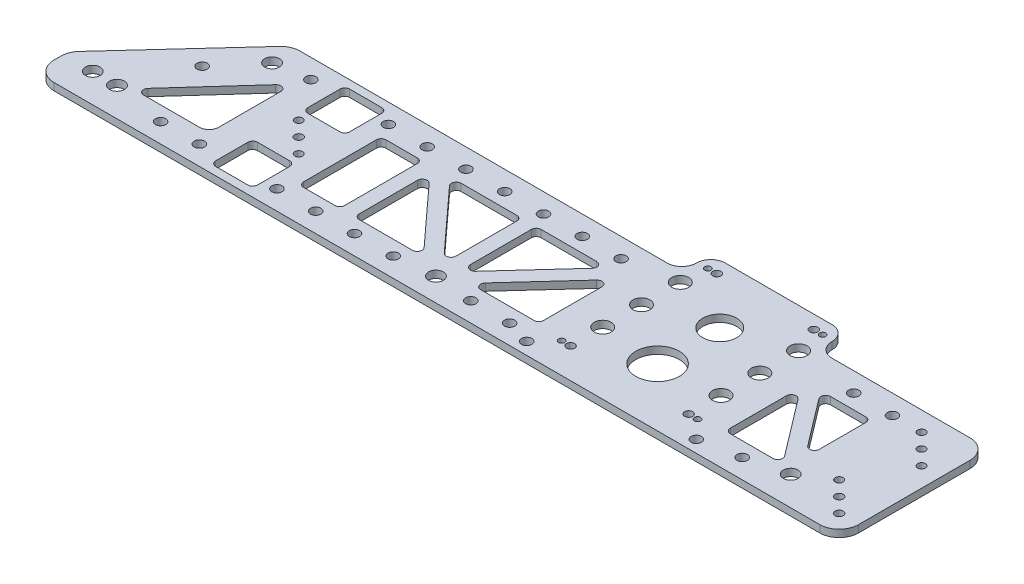
from build123d import *

# Parameters (mm, degrees)
SKETCH1_R           = 4.826
SKETCH1_R_2         = 5.5626
SKETCH1_R_3         = 14.28115
SKETCH1_R_4         = 11.10615
SKETCH1_R_5         = 3.3782
SKETCH1_R_6         = 2.667
SKETCH1_R_7         = 2.032
SKETCH1_R_8         = 2.5527
BOSS_EXTRUDE1_DEPTH = 4.7625


with BuildPart() as part:
    # Sketch1 → Boss-Extrude1 (new body)
    with BuildSketch(Plane.XZ):
        with BuildLine():
            Line((335.06917663, -117.475), (404.91917663, -117.475))
            ThreePointArc((404.91917663, -117.475), (411.654368721, -114.685192091), (414.44417663, -107.95))
            ThreePointArc((414.44417663, -107.95), (417.233984539, -101.214807909), (423.96917663, -98.425))
            Line((423.96917663, -98.425), (514.35, -98.425))
            ThreePointArc((514.35, -98.425), (523.330256121, -94.705256121), (527.05, -85.725))
            Line((527.05, -85.725), (527.05, -12.7))
            ThreePointArc((527.05, -12.7), (523.330256121, -3.719743879), (514.35, 0))
            Line((514.35, 0), (12.7, 0))
            ThreePointArc((12.7, 0), (3.719743879, -3.719743879), (0, -12.7))
            Line((0, -12.7), (0, -17.28490713))
            ThreePointArc((0, -17.28490713), (0.863919752, -21.888949307), (3.338142419, -25.866609912))
            Line((3.338142419, -25.866609912), (66.074894217, -94.306702782))
            ThreePointArc((66.074894217, -94.306702782), (70.322928635, -97.34992205), (75.436751798, -98.425))
            Line((75.436751798, -98.425), (316.01917663, -98.425))
            ThreePointArc((316.01917663, -98.425), (322.754368721, -101.214807909), (325.54417663, -107.95))
            ThreePointArc((325.54417663, -107.95), (328.333984539, -114.685192091), (335.06917663, -117.475))
        make_face()
        with Locations((34.925, -19.05)):
            Circle(SKETCH1_R, mode=Mode.SUBTRACT)
        with Locations((408.74516284, -66.3194)):
            Circle(SKETCH1_R_2, mode=Mode.SUBTRACT)
        with Locations((331.243190421, -40.9194)):
            Circle(SKETCH1_R_2, mode=Mode.SUBTRACT)
        with Locations((331.243190421, -66.3194)):
            Circle(SKETCH1_R_2, mode=Mode.SUBTRACT)
        with Locations((369.99417663, -38.1)):
            Circle(SKETCH1_R_3, mode=Mode.SUBTRACT)
        with Locations((247.65, -15.24)):
            Circle(SKETCH1_R, mode=Mode.SUBTRACT)
        with Locations((19.05, -19.05)):
            Circle(SKETCH1_R, mode=Mode.SUBTRACT)
        with Locations((476.25, -19.05)):
            Circle(SKETCH1_R, mode=Mode.SUBTRACT)
        with Locations((369.99417663, -78.8162)):
            Circle(SKETCH1_R_4, mode=Mode.SUBTRACT)
        with Locations((331.243190421, -91.7194)):
            Circle(SKETCH1_R_2, mode=Mode.SUBTRACT)
        with Locations((408.74516284, -91.7194)):
            Circle(SKETCH1_R_2, mode=Mode.SUBTRACT)
        with Locations((408.74516284, -40.9194)):
            Circle(SKETCH1_R_2, mode=Mode.SUBTRACT)
        with Locations((314.41897663, -7.9248)):
            Circle(SKETCH1_R_5, mode=Mode.SUBTRACT)
        with Locations((338.24417663, -108.6612)):
            Circle(SKETCH1_R_6, mode=Mode.SUBTRACT)
        with Locations((425.56937663, -7.9248)):
            Circle(SKETCH1_R_5, mode=Mode.SUBTRACT)
        with Locations((401.74417663, -108.6612)):
            Circle(SKETCH1_R_6, mode=Mode.SUBTRACT)
        with Locations((331.33537663, -19.7866)):
            Circle(SKETCH1_R_6, mode=Mode.SUBTRACT)
        with Locations((408.65297663, -19.7866)):
            Circle(SKETCH1_R_6, mode=Mode.SUBTRACT)
        with Locations((332.40217663, -108.6612)):
            Circle(SKETCH1_R_7, mode=Mode.SUBTRACT)
        with Locations((325.49337663, -19.7866)):
            Circle(SKETCH1_R_7, mode=Mode.SUBTRACT)
        with Locations((407.58617663, -108.6612)):
            Circle(SKETCH1_R_7, mode=Mode.SUBTRACT)
        with Locations((414.49497663, -19.7866)):
            Circle(SKETCH1_R_7, mode=Mode.SUBTRACT)
        with Locations((73.025, -82.55)):
            Circle(SKETCH1_R, mode=Mode.SUBTRACT)
        with Locations((95.25, -12.7)):
            Circle(SKETCH1_R_5, mode=Mode.SUBTRACT)
        with Locations((95.25, -85.725)):
            Circle(SKETCH1_R_5, mode=Mode.SUBTRACT)
        with Locations((146.05, -12.7)):
            Circle(SKETCH1_R_5, mode=Mode.SUBTRACT)
        with Locations((146.05, -85.725)):
            Circle(SKETCH1_R_5, mode=Mode.SUBTRACT)
        with Locations((171.45, -12.7)):
            Circle(SKETCH1_R_5, mode=Mode.SUBTRACT)
        with Locations((171.45, -85.725)):
            Circle(SKETCH1_R_5, mode=Mode.SUBTRACT)
        with Locations((196.85, -12.7)):
            Circle(SKETCH1_R_5, mode=Mode.SUBTRACT)
        with Locations((196.85, -85.725)):
            Circle(SKETCH1_R_5, mode=Mode.SUBTRACT)
        with Locations((222.25, -12.7)):
            Circle(SKETCH1_R_5, mode=Mode.SUBTRACT)
        with Locations((222.25, -85.725)):
            Circle(SKETCH1_R_5, mode=Mode.SUBTRACT)
        with Locations((247.65, -85.725)):
            Circle(SKETCH1_R_5, mode=Mode.SUBTRACT)
        with Locations((273.05, -12.7)):
            Circle(SKETCH1_R_5, mode=Mode.SUBTRACT)
        with Locations((273.05, -85.725)):
            Circle(SKETCH1_R_5, mode=Mode.SUBTRACT)
        with Locations((298.45, -12.7)):
            Circle(SKETCH1_R_5, mode=Mode.SUBTRACT)
        with Locations((298.45, -85.725)):
            Circle(SKETCH1_R_5, mode=Mode.SUBTRACT)
        with Locations((450.85, -12.7)):
            Circle(SKETCH1_R_5, mode=Mode.SUBTRACT)
        with Locations((476.25, -85.725)):
            Circle(SKETCH1_R_5, mode=Mode.SUBTRACT)
        with Locations((450.85, -85.725)):
            Circle(SKETCH1_R_5, mode=Mode.SUBTRACT)
        with Locations((495.3, -85.725)):
            Circle(SKETCH1_R_8, mode=Mode.SUBTRACT)
        with Locations((504.825, -76.2)):
            Circle(SKETCH1_R_8, mode=Mode.SUBTRACT)
        with Locations((514.35, -66.675)):
            Circle(SKETCH1_R_8, mode=Mode.SUBTRACT)
        with Locations((504.825, -22.225)):
            Circle(SKETCH1_R_6, mode=Mode.SUBTRACT)
        with Locations((495.3, -31.75)):
            Circle(SKETCH1_R_8, mode=Mode.SUBTRACT)
        with Locations((514.35, -12.7)):
            Circle(SKETCH1_R_6, mode=Mode.SUBTRACT)
        with Locations((123.825, -49.2125)):
            Circle(SKETCH1_R_6, mode=Mode.SUBTRACT)
        with Locations((133.35, -39.6875)):
            Circle(SKETCH1_R_8, mode=Mode.SUBTRACT)
        with Locations((114.3, -58.7375)):
            Circle(SKETCH1_R_8, mode=Mode.SUBTRACT)
        with Locations((69.85, -12.7)):
            Circle(SKETCH1_R_5, mode=Mode.SUBTRACT)
        with Locations((51.950539741, -57.756517342)):
            Circle(SKETCH1_R_5, mode=Mode.SUBTRACT)
        with BuildLine():
            Line((137.541, -68.834), (137.541, -89.916))
            ThreePointArc((137.541, -89.916), (136.61106403, -92.16106403), (134.366, -93.091))
            Line((134.366, -93.091), (113.284, -93.091))
            ThreePointArc((113.284, -93.091), (111.03893597, -92.16106403), (110.109, -89.916))
            Line((110.109, -89.916), (110.109, -68.834))
            ThreePointArc((110.109, -68.834), (111.03893597, -66.58893597), (113.284, -65.659))
            Line((113.284, -65.659), (134.366, -65.659))
            ThreePointArc((134.366, -65.659), (136.61106403, -66.58893597), (137.541, -68.834))
        make_face(mode=Mode.SUBTRACT)
        with BuildLine():
            Line((137.541, -8.509), (137.541, -29.591))
            ThreePointArc((137.541, -29.591), (136.61106403, -31.83606403), (134.366, -32.766))
            Line((134.366, -32.766), (113.284, -32.766))
            ThreePointArc((113.284, -32.766), (111.03893597, -31.83606403), (110.109, -29.591))
            Line((110.109, -29.591), (110.109, -8.509))
            ThreePointArc((110.109, -8.509), (111.03893597, -6.26393597), (113.284, -5.334))
            Line((113.284, -5.334), (134.366, -5.334))
            ThreePointArc((134.366, -5.334), (136.61106403, -6.26393597), (137.541, -8.509))
        make_face(mode=Mode.SUBTRACT)
        with BuildLine():
            Line((86.545623901, -71.37201882), (46.879170981, -27.530149804))
            ThreePointArc((46.879170981, -27.530149804), (46.33149172, -24.112094846), (49.23354708, -22.225))
            Line((49.23354708, -22.225), (85.725, -22.225))
            ThreePointArc((85.725, -22.225), (90.215128061, -24.084871939), (92.075, -28.575))
            Line((92.075, -28.575), (92.075, -69.241869017))
            ThreePointArc((92.075, -69.241869017), (90.041376556, -72.204618509), (86.545623901, -71.37201882))
        make_face(mode=Mode.SUBTRACT)
        with BuildLine():
            Line((463.980698305, -27.321322562), (436.034552363, -64.087036098))
            ThreePointArc((436.034552363, -64.087036098), (432.493157106, -65.174533525), (430.33187663, -62.165713536))
            Line((430.33187663, -62.165713536), (430.33187663, -25.4))
            ThreePointArc((430.33187663, -25.4), (431.2618126, -23.15493597), (433.50687663, -22.225))
            Line((433.50687663, -22.225), (461.453022572, -22.225))
            ThreePointArc((461.453022572, -22.225), (464.297387539, -23.989250932), (463.980698305, -27.321322562))
        make_face(mode=Mode.SUBTRACT)
        with BuildLine():
            Line((292.051741244, -76.2), (255.5875, -76.2))
            ThreePointArc((255.5875, -76.2), (253.34243597, -75.27006403), (252.4125, -73.025))
            Line((252.4125, -73.025), (252.4125, -33.144184818))
            ThreePointArc((252.4125, -33.144184818), (254.43837015, -30.184433885), (257.930689347, -31.001735592))
            Line((257.930689347, -31.001735592), (294.394930591, -70.882550774))
            ThreePointArc((294.394930591, -70.882550774), (294.957158709, -74.305302446), (292.051741244, -76.2))
        make_face(mode=Mode.SUBTRACT)
        with BuildLine():
            Line((270.017235386, -22.225), (304.89397663, -22.225))
            ThreePointArc((304.89397663, -22.225), (307.13904066, -23.15493597), (308.06897663, -25.4))
            Line((308.06897663, -25.4), (308.06897663, -63.544571894))
            ThreePointArc((308.06897663, -63.544571894), (306.04310648, -66.504322828), (302.550787284, -65.68702112))
            Line((302.550787284, -65.68702112), (267.674046039, -27.542449226))
            ThreePointArc((267.674046039, -27.542449226), (267.111817921, -24.119697554), (270.017235386, -22.225))
        make_face(mode=Mode.SUBTRACT)
        with BuildLine():
            Line((239.7125, -76.2), (203.248258756, -76.2))
            ThreePointArc((203.248258756, -76.2), (200.342841291, -74.305302446), (200.905069409, -70.882550774))
            Line((200.905069409, -70.882550774), (237.369310653, -31.001735592))
            ThreePointArc((237.369310653, -31.001735592), (240.86162985, -30.184433885), (242.8875, -33.144184818))
            Line((242.8875, -33.144184818), (242.8875, -73.025))
            ThreePointArc((242.8875, -73.025), (241.95756403, -75.27006403), (239.7125, -76.2))
        make_face(mode=Mode.SUBTRACT)
        with BuildLine():
            Line((190.40602337, -22.225), (225.282764614, -22.225))
            ThreePointArc((225.282764614, -22.225), (228.188182079, -24.119697554), (227.625953961, -27.542449226))
            Line((227.625953961, -27.542449226), (192.749212716, -65.68702112))
            ThreePointArc((192.749212716, -65.68702112), (189.25689352, -66.504322828), (187.23102337, -63.544571894))
            Line((187.23102337, -63.544571894), (187.23102337, -25.4))
            ThreePointArc((187.23102337, -25.4), (188.16095934, -23.15493597), (190.40602337, -22.225))
        make_face(mode=Mode.SUBTRACT)
        with BuildLine():
            Line((177.70602337, -25.4), (177.70602337, -73.025))
            ThreePointArc((177.70602337, -73.025), (176.7760874, -75.27006403), (174.53102337, -76.2))
            Line((174.53102337, -76.2), (153.9875, -76.2))
            ThreePointArc((153.9875, -76.2), (151.74243597, -75.27006403), (150.8125, -73.025))
            Line((150.8125, -73.025), (150.8125, -25.4))
            ThreePointArc((150.8125, -25.4), (151.74243597, -23.15493597), (153.9875, -22.225))
            Line((153.9875, -22.225), (174.53102337, -22.225))
            ThreePointArc((174.53102337, -22.225), (176.7760874, -23.15493597), (177.70602337, -25.4))
        make_face(mode=Mode.SUBTRACT)
        with BuildLine():
            Line((471.4875, -42.609286464), (471.4875, -73.025))
            ThreePointArc((471.4875, -73.025), (470.55756403, -75.27006403), (468.3125, -76.2))
            Line((468.3125, -76.2), (445.193080094, -76.2))
            ThreePointArc((445.193080094, -76.2), (442.348715126, -74.435749068), (442.665404361, -71.103677438))
            Line((442.665404361, -71.103677438), (465.784824267, -40.687963902))
            ThreePointArc((465.784824267, -40.687963902), (469.326219524, -39.600466475), (471.4875, -42.609286464))
        make_face(mode=Mode.SUBTRACT)
    extrude(amount=-BOSS_EXTRUDE1_DEPTH)


solid = part.part
